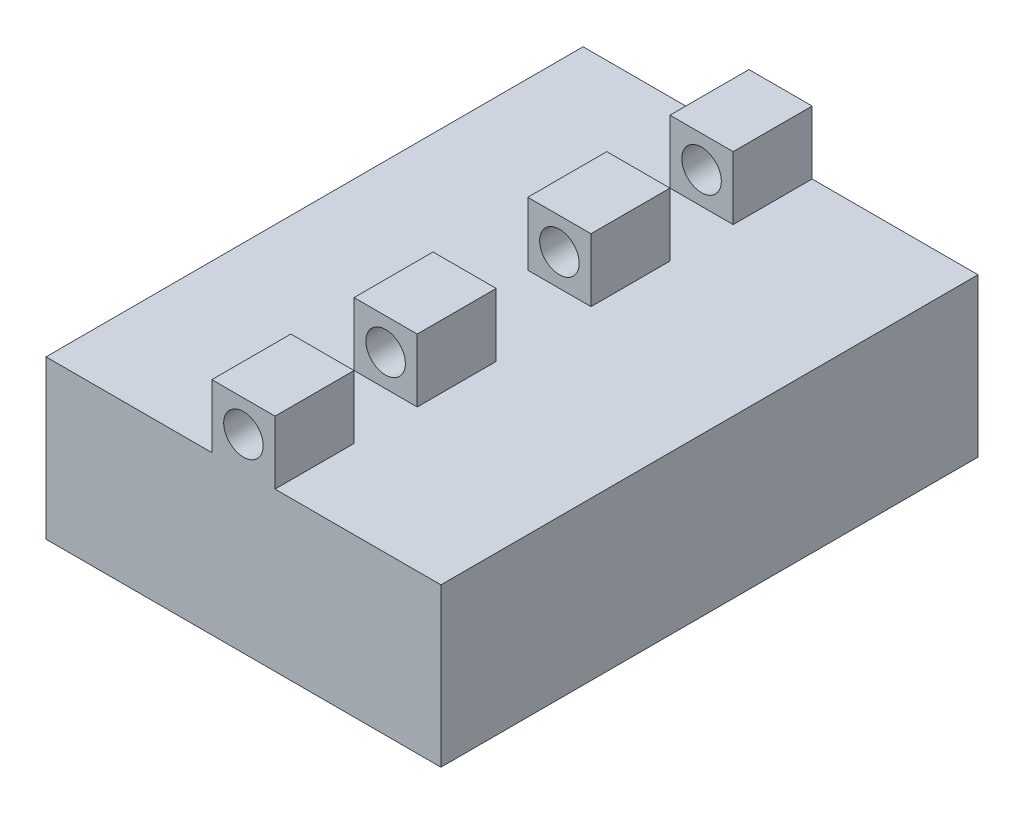
from build123d import *

# Parameters (mm, degrees)
SKETCH1_W           = 250
SKETCH1_H           = 340
BOSS_EXTRUDE1_DEPTH = 100
SKETCH3_R           = 12.5
BOSS_EXTRUDE2_DEPTH = 340
SKETCH4_W           = 40
SKETCH4_H           = 40
SKETCH4_H_2         = 60
CUT_EXTRUDE1_DEPTH  = 40


with BuildPart() as part:
    # Sketch1 → Boss-Extrude1 (new body)
    with BuildSketch(Plane(origin=(0, 0, 0), x_dir=(1, 0, 0), z_dir=(0, 1, 0))):
        with Locations((125, -170)):
            Rectangle(SKETCH1_W, SKETCH1_H)
    extrude(amount=BOSS_EXTRUDE1_DEPTH)

    # Sketch3 → Boss-Extrude2 (add, through all)
    with BuildSketch(Plane.XY.offset(340)):
        Polygon((105, 100), (145, 100), (145, 120), (145, 132.5), (145, 140), (105, 140), (105, 132.5), (105, 120), align=None)
        with Locations((125, 120)):
            Circle(SKETCH3_R, mode=Mode.SUBTRACT)
    extrude(amount=-BOSS_EXTRUDE2_DEPTH)

    # Sketch4 → Cut-Extrude1 (cut)
    with BuildSketch(Plane(origin=(0, 140, 0), x_dir=(1, 0, 0), z_dir=(0, 1, 0))):
        with Locations((125, -270)):
            Rectangle(SKETCH4_W, SKETCH4_H)
        with Locations((125, -70)):
            Rectangle(SKETCH4_W, SKETCH4_H)
        with Locations((125, -170)):
            Rectangle(SKETCH4_W, SKETCH4_H_2)
    extrude(amount=-CUT_EXTRUDE1_DEPTH, mode=Mode.SUBTRACT)


solid = part.part
